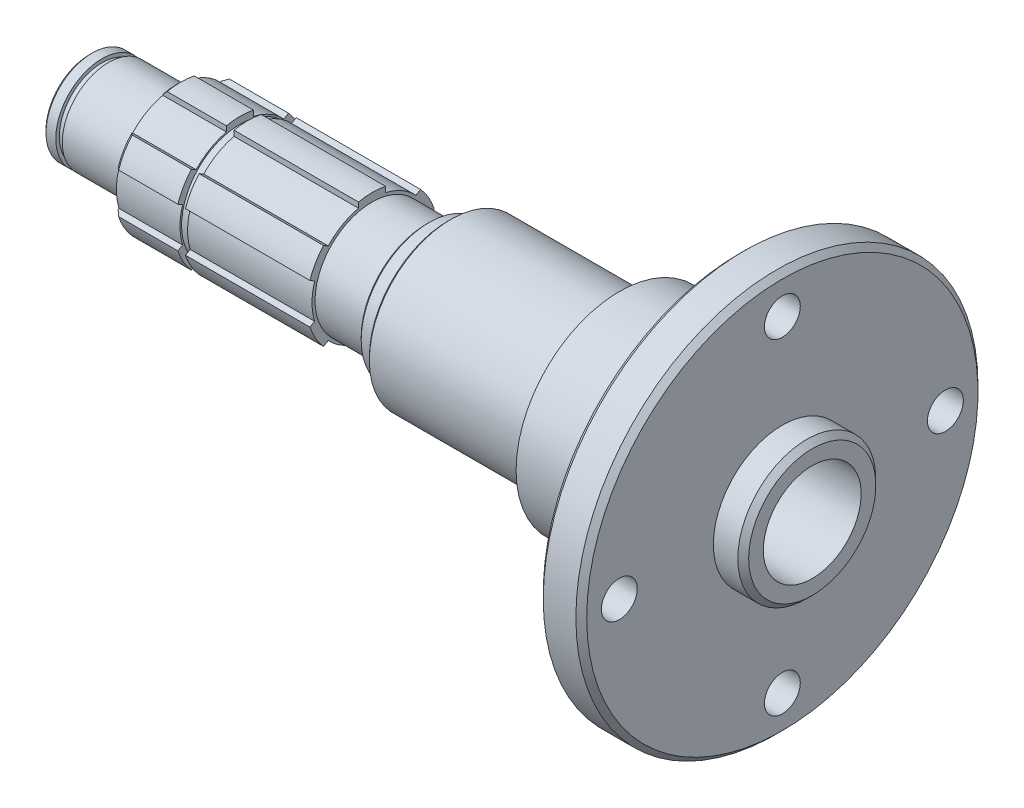
from build123d import *

# Parameters (mm, degrees)
ESQUISSE1_W                  = 135
ESQUISSE1_H                  = 37.5
D_GAGEMENT_M61_D             = 6.6
R_P_TITION_CIRCULAIRE1_COUNT = 4
CONG_1_R                     = 2
ESQUISSE12_W                 = 1.4
ESQUISSE12_H                 = 1.27
ESQUISSE7_R                  = 13.345253716
ENL_V_MAT_EXTRU_1_DEPTH      = 36
ESQUISSE8_W                  = 1.2
ESQUISSE8_H                  = 0.65
CHANFREIN1_SIZE              = 0.8
CHANFREIN2_SIZE              = 0.5
CONG_2_R                     = 1
CHANFREIN3_SIZE              = 0.5
CHANFREIN4_SIZE              = 1
CHANFREIN5_SIZE              = 1
CHANFREIN6_SIZE              = 0.5


with BuildPart() as part:
    # Esquisse1 → Révolution1 (revolve)
    with BuildSketch(Plane.XY, mode=Mode.PRIVATE) as r_volution1_sk:
        with Locations((67.5, 18.75)):
            Rectangle(ESQUISSE1_W, ESQUISSE1_H)
    revolve(r_volution1_sk.sketch.rotate(Axis((-44.672408566, 0, 0), (1, 0, 0)), 90), axis=Axis((-44.672408566, 0, 0), (1, 0, 0)))  # turned: the seam where the file's is

    # Esquisse2 → Enlèvement de matière-Révolution1 (revolve, cut)
    with BuildSketch(Plane.XY, mode=Mode.PRIVATE) as enl_vement_de_mati_re_r_volution1_sk:
        Polygon((0, 0), (0, 37.5), (135, 37.5), (135, 0), (134, 0), (134, 12.7), (128.5, 12.7), (128.5, 37), (120.5, 37), (120.5, 19), (98.5, 19), (98.5, 15), (53, 15), (53, 12.02), (17, 12.02), (17, 8.5), (1, 8.5), (1, 0), align=None)
    revolve(enl_vement_de_mati_re_r_volution1_sk.sketch.rotate(Axis((-11.79532693, 0, 0), (1, 0, 0)), 90), axis=Axis((-11.79532693, 0, 0), (1, 0, 0)), mode=Mode.SUBTRACT)  # turned: the seam where the file's is

    # Dégagement M61 (through all)
    with Locations(Plane(origin=(128.5, 0, 0), x_dir=(0, 0, -1), z_dir=(1, 0, 0))):
        with Locations((0, 30)):
            d_gagement_m61 = Hole(D_GAGEMENT_M61_D / 2)

    # Répétition circulaire1: Dégagement M61 ×4 about axis
    r_p_tition_circulaire1_axis = Axis((0, 0, 0), (1, 0, 0))
    for i in range(1, R_P_TITION_CIRCULAIRE1_COUNT):
        add(d_gagement_m61.rotate(r_p_tition_circulaire1_axis, i * 360 / R_P_TITION_CIRCULAIRE1_COUNT), mode=Mode.SUBTRACT)

    # Congé1
    cong_1_edges = [part.edges().sort_by_distance(p)[0] for p in [
        (120.5, 0, -19),
    ]]
    fillet(cong_1_edges, radius=CONG_1_R)

    # Esquisse12 → Enlèvement de matière-Révolution6 (revolve, cut)
    with BuildSketch(Plane.XY, mode=Mode.PRIVATE) as enl_vement_de_mati_re_r_volution6_sk:
        with Locations((29.4, 11.385)):
            Rectangle(ESQUISSE12_W, ESQUISSE12_H)
    revolve(enl_vement_de_mati_re_r_volution6_sk.sketch.rotate(Axis((0, 0, 0), (-1, 0, 0)), 270), axis=Axis((0, 0, 0), (-1, 0, 0)), mode=Mode.SUBTRACT)  # turned: the seam where the file's is

    # Esquisse7 → Enlèv. mat.-Extru.1 (cut)
    with BuildSketch(Plane.ZY.offset(-17)):
        Circle(ESQUISSE7_R)
        with BuildLine():
            Line((11.43198409, 3.713507746), (10.571447044, 3.216676451))
            ThreePointArc((10.571447044, 3.216676451), (11.05, 0), (10.571447044, -3.216676451))
            Line((10.571447044, -3.216676451), (11.43198409, -3.713507746))
            ThreePointArc((11.43198409, -3.713507746), (10.409625353, -6.01), (8.93198409, -8.043634764))
            Line((8.93198409, -8.043634764), (8.071447044, -7.54680347))
            ThreePointArc((8.071447044, -7.54680347), (5.525, -9.569580712), (2.5, -10.763479921))
            Line((2.5, -10.763479921), (2.5, -11.75714251))
            ThreePointArc((2.5, -11.75714251), (0, -12.02), (-2.5, -11.75714251))
            Line((-2.5, -11.75714251), (-2.5, -10.763479921))
            ThreePointArc((-2.5, -10.763479921), (-5.525, -9.569580712), (-8.071447044, -7.54680347))
            Line((-8.071447044, -7.54680347), (-8.93198409, -8.043634764))
            ThreePointArc((-8.93198409, -8.043634764), (-10.409625353, -6.01), (-11.43198409, -3.713507746))
            Line((-11.43198409, -3.713507746), (-10.571447044, -3.216676451))
            ThreePointArc((-10.571447044, -3.216676451), (-11.05, 0), (-10.571447044, 3.216676451))
            Line((-10.571447044, 3.216676451), (-11.43198409, 3.713507746))
            ThreePointArc((-11.43198409, 3.713507746), (-10.409625353, 6.01), (-8.93198409, 8.043634764))
            Line((-8.93198409, 8.043634764), (-8.071447044, 7.54680347))
            ThreePointArc((-8.071447044, 7.54680347), (-5.525, 9.569580712), (-2.5, 10.763479921))
            Line((-2.5, 10.763479921), (-2.5, 11.75714251))
            ThreePointArc((-2.5, 11.75714251), (0, 12.02), (2.5, 11.75714251))
            Line((2.5, 11.75714251), (2.5, 10.763479921))
            ThreePointArc((2.5, 10.763479921), (5.525, 9.569580712), (8.071447044, 7.54680347))
            Line((8.071447044, 7.54680347), (8.93198409, 8.043634764))
            ThreePointArc((8.93198409, 8.043634764), (10.409625353, 6.01), (11.43198409, 3.713507746))
        make_face(mode=Mode.SUBTRACT)
    extrude(amount=-ENL_V_MAT_EXTRU_1_DEPTH, mode=Mode.SUBTRACT)

    # Esquisse8 → Enlèvement de matière-Révolution3 (revolve, cut)
    with BuildSketch(Plane.XY, mode=Mode.PRIVATE) as enl_vement_de_mati_re_r_volution3_sk:
        with Locations((3.9, 8.175)):
            Rectangle(ESQUISSE8_W, ESQUISSE8_H)
    revolve(enl_vement_de_mati_re_r_volution3_sk.sketch.rotate(Axis((-5.65, 0, 0), (1, 0, 0)), 90), axis=Axis((-5.65, 0, 0), (1, 0, 0)), mode=Mode.SUBTRACT)  # turned: the seam where the file's is

    # Chanfrein1
    chanfrein1_edges = [part.edges().sort_by_distance(p)[0] for p in [
        (17, 6.01, 10.409625353),
        (17, 12.02, 0),
        (17, 6.01, -10.409625353),
        (17, -6.01, -10.409625353),
        (17, -12.02, 0),
        (17, -6.01, 10.409625353),
    ]]
    chamfer(chanfrein1_edges, length=CHANFREIN1_SIZE)

    # Esquisse9 → Enlèvement de matière-Révolution4 (revolve, cut)
    with BuildSketch(Plane.XY, mode=Mode.PRIVATE) as enl_vement_de_mati_re_r_volution4_sk:
        Polygon((53, 15), (67, 15), (67, 12.5), (63, 12.5), (63, 10.5), (53, 10.5), align=None)
    revolve(enl_vement_de_mati_re_r_volution4_sk.sketch.rotate(Axis((-5.65, 0, 0), (1, 0, 0)), 90), axis=Axis((-5.65, 0, 0), (1, 0, 0)), mode=Mode.SUBTRACT)  # turned: the seam where the file's is

    # Chanfrein2
    chanfrein2_edges = [part.edges().sort_by_distance(p)[0] for p in [
        (67, 0, -15),
    ]]
    chamfer(chanfrein2_edges, length=CHANFREIN2_SIZE)

    # Congé2
    cong_2_edges = [part.edges().sort_by_distance(p)[0] for p in [
        (63, 0, -10.5),
    ]]
    fillet(cong_2_edges, radius=CONG_2_R)

    # Chanfrein3
    chanfrein3_edges = [part.edges().sort_by_distance(p)[0] for p in [
        (1, 0, -8.5),
    ]]
    chamfer(chanfrein3_edges, length=CHANFREIN3_SIZE)

    # Chanfrein4
    chanfrein4_edges = [part.edges().sort_by_distance(p)[0] for p in [
        (128.5, 0, -37),
        (120.5, 0, -37),
    ]]
    chamfer(chanfrein4_edges, length=CHANFREIN4_SIZE)

    # Chanfrein5
    chanfrein5_edges = [part.edges().sort_by_distance(p)[0] for p in [
        (134, 0, -12.7),
    ]]
    chamfer(chanfrein5_edges, length=CHANFREIN5_SIZE)

    # Chanfrein6
    chanfrein6_edges = [part.edges().sort_by_distance(p)[0] for p in [
        (63, 0, -12.5),
    ]]
    chamfer(chanfrein6_edges, length=CHANFREIN6_SIZE)

    # Esquisse13 → Enlèvement de matière-Révolution7 (revolve, cut)
    with BuildSketch(Plane.XY, mode=Mode.PRIVATE) as enl_vement_de_mati_re_r_volution7_sk:
        Polygon((134, 9), (74.196152423, 9), (69, 0), (134, 0), align=None)
    revolve(enl_vement_de_mati_re_r_volution7_sk.sketch.rotate(Axis((-5.65, 0, 0), (1, 0, 0)), 90), axis=Axis((-5.65, 0, 0), (1, 0, 0)), mode=Mode.SUBTRACT)  # turned: the seam where the file's is


solid = part.part
